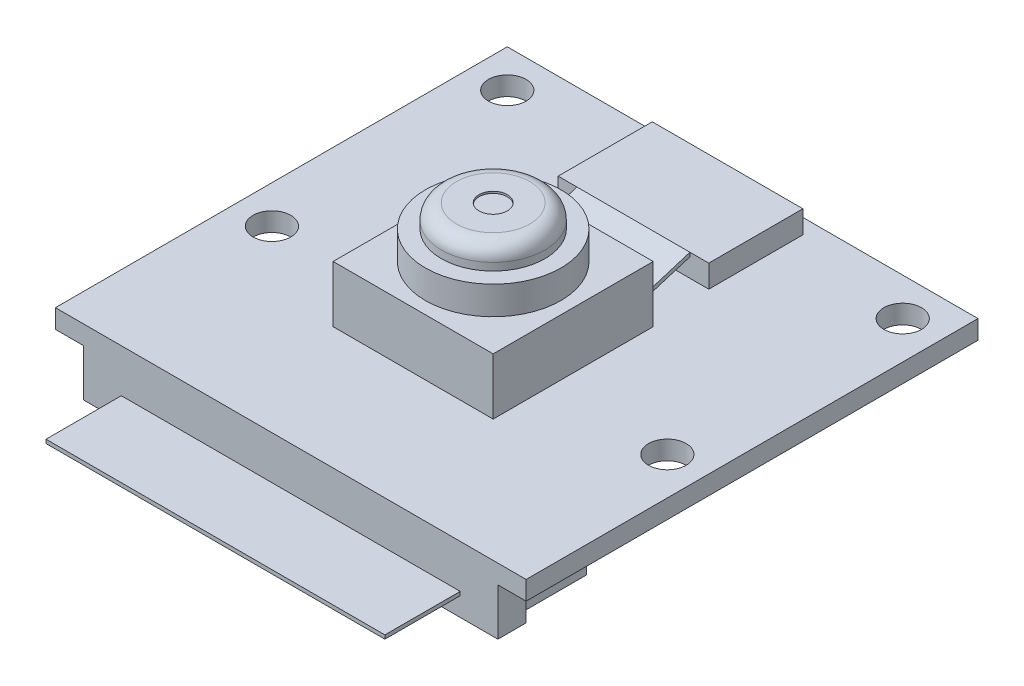
from build123d import *

# Parameters (mm, degrees)
SKETCH_1_W                     = 25
SKETCH_1_H                     = 24
EXTRUDE_1_DEPTH                = 1
CUT_EXTRUDE_1_REACH            = 3
SKETCH_2_R                     = 1
SKETCH_3_W                     = 8.5
SKETCH_3_H                     = 8.5
EXTRUDE_2_DEPTH                = 3
SKETCH_4_R                     = 3.6
EXTRUDE_3_DEPTH                = 1.5
SKETCH_5_R                     = 2.75
EXTRUDE_4_DEPTH                = 1.2
FILLET_1_R                     = 0.8
SKETCH_6_R                     = 0.75
CUT_EXTRUDE_2_DEPTH            = 0.1
SKETCH_7_W                     = 8
SKETCH_7_H                     = 5
EXTRUDE_5_DEPTH                = 1.2
EXTRUDE_6_DEPTH                = 3
EXTRUDE_6_DEPTH_BACK           = 3
SKETCH_9_W                     = 22
SKETCH_9_H                     = 1.5
EXTRUDE_7_DEPTH                = 2.5
SKETCH_12_W                    = 21
SKETCH_12_H                    = 3.7
EXTRUDE_8_DEPTH                = 2.4
EXTRUDE_9_DEPTH                = 0.1
PATTERN_LINEAR_1_COUNT         = 8
PATTERN_LINEAR_1_PITCH         = 1.2
PATTERN_LINEAR_1_COL_COUNT     = 8
PATTERN_LINEAR_1_COL_PITCH     = 1.2
SKETCH_14_W                    = 3
SKETCH_14_H                    = 1.5
EXTRUDE_10_DEPTH               = 1
EXTRUDE_11_DEPTH               = 0.15
PATTERN_LINEAR_2_COUNT         = 2
PATTERN_LINEAR_2_PITCH         = 1
PATTERN_LINEAR_2_COL_COUNT     = 2
PATTERN_LINEAR_2_COL_PITCH     = 1
MIRROR_1_COPY_1_DEPTH          = 0.15
MIRROR_1_COPY_2_DEPTH          = 0.15
PATTERN_LINEAR_3_COUNT         = 3
PATTERN_LINEAR_3_PITCH         = 5
PATTERN_LINEAR_3_COPY_1_DEPTH  = 0.15
PATTERN_LINEAR_3_COPY_2_DEPTH  = 0.15
PATTERN_LINEAR_3_COPY_3_DEPTH  = 0.15
PATTERN_LINEAR_3_COPY_4_DEPTH  = 0.15
PATTERN_LINEAR_3_COPY_5_DEPTH  = 0.15
PATTERN_LINEAR_3_COPY_6_DEPTH  = 0.15
PATTERN_LINEAR_3_COPY_7_DEPTH  = 0.15
PATTERN_LINEAR_3_COPY_8_DEPTH  = 0.15
PATTERN_LINEAR_3_COPY_9_DEPTH  = 0.15
PATTERN_LINEAR_3_COPY_10_DEPTH = 0.15
SKETCH_16_W                    = 2.5
SKETCH_16_H                    = 3
EXTRUDE_12_DEPTH               = 1.2
FILLET_2_R                     = 0.2
SKETCH_17_W                    = 18
SKETCH_17_H                    = 0.2
EXTRUDE_13_DEPTH               = 4


with BuildPart() as part:
    # 草图1 → 凸台-拉伸1 (new body)
    with BuildSketch(Plane(origin=(0, 0, 0), x_dir=(1, 0, 0), z_dir=(0, 1, 0))):
        Rectangle(SKETCH_1_W, SKETCH_1_H)
    extrude(amount=EXTRUDE_1_DEPTH)

    # 草图2 → 切除-拉伸1 (cut, up to next)
    with BuildSketch(Plane(origin=(0, 1, 0), x_dir=(1, 0, 0), z_dir=(0, 1, 0)), mode=Mode.PRIVATE) as cut_extrude_1_sk1:
        with Locations((-10.5, 10)):
            Circle(SKETCH_2_R)
    cut_extrude_1_tool1 = extrude(cut_extrude_1_sk1.sketch, amount=-CUT_EXTRUDE_1_REACH, mode=Mode.PRIVATE) & part.part
    add(cut_extrude_1_tool1.solids().sort_by_distance((-10.5, 1, -10))[0], mode=Mode.SUBTRACT)
    # 草图2 → 切除-拉伸1 (cut, up to next)
    with BuildSketch(Plane(origin=(0, 1, 0), x_dir=(1, 0, 0), z_dir=(0, 1, 0)), mode=Mode.PRIVATE) as cut_extrude_1_sk2:
        with Locations((-10.5, -2.5)):
            Circle(SKETCH_2_R)
    cut_extrude_1_tool2 = extrude(cut_extrude_1_sk2.sketch, amount=-CUT_EXTRUDE_1_REACH, mode=Mode.PRIVATE) & part.part
    add(cut_extrude_1_tool2.solids().sort_by_distance((-10.5, 1, 2.5))[0], mode=Mode.SUBTRACT)
    # 草图2 → 切除-拉伸1 (cut, up to next)
    with BuildSketch(Plane(origin=(0, 1, 0), x_dir=(1, 0, 0), z_dir=(0, 1, 0)), mode=Mode.PRIVATE) as cut_extrude_1_sk3:
        with Locations((10.5, -2.5)):
            Circle(SKETCH_2_R)
    cut_extrude_1_tool3 = extrude(cut_extrude_1_sk3.sketch, amount=-CUT_EXTRUDE_1_REACH, mode=Mode.PRIVATE) & part.part
    add(cut_extrude_1_tool3.solids().sort_by_distance((10.5, 1, 2.5))[0], mode=Mode.SUBTRACT)
    # 草图2 → 切除-拉伸1 (cut, up to next)
    with BuildSketch(Plane(origin=(0, 1, 0), x_dir=(1, 0, 0), z_dir=(0, 1, 0)), mode=Mode.PRIVATE) as cut_extrude_1_sk4:
        with Locations((10.5, 10)):
            Circle(SKETCH_2_R)
    cut_extrude_1_tool4 = extrude(cut_extrude_1_sk4.sketch, amount=-CUT_EXTRUDE_1_REACH, mode=Mode.PRIVATE) & part.part
    add(cut_extrude_1_tool4.solids().sort_by_distance((10.5, 1, -10))[0], mode=Mode.SUBTRACT)

    # 草图3 → 凸台-拉伸2 (add)
    with BuildSketch(Plane(origin=(0, 1, 0), x_dir=(1, 0, 0), z_dir=(0, 1, 0))):
        with Locations((0, -1.25)):
            Rectangle(SKETCH_3_W, SKETCH_3_H)
    extrude(amount=EXTRUDE_2_DEPTH)

    # 草图4 → 凸台-拉伸3 (add)
    with BuildSketch(Plane(origin=(0, 4, 0), x_dir=(1, 0, 0), z_dir=(0, 1, 0))):
        with Locations((0, -1.25)):
            Circle(SKETCH_4_R)
    extrude(amount=EXTRUDE_3_DEPTH)

    # 草图5 → 凸台-拉伸4 (add)
    with BuildSketch(Plane(origin=(0, 5.5, 0), x_dir=(1, 0, 0), z_dir=(0, 1, 0))):
        with Locations((0, -1.25)):
            Circle(SKETCH_5_R)
    extrude(amount=EXTRUDE_4_DEPTH)

    # 圆角1
    fillet_1_edges = [part.edges().sort_by_distance(p)[0] for p in [
        (-2.75, 6.7, 1.25),
    ]]
    fillet(fillet_1_edges, radius=FILLET_1_R)

    # 草图6 → 切除-拉伸2 (cut)
    with BuildSketch(Plane(origin=(0, 6.7, 0), x_dir=(1, 0, 0), z_dir=(0, 1, 0))):
        with Locations((0, -1.25)):
            Circle(SKETCH_6_R)
    extrude(amount=-CUT_EXTRUDE_2_DEPTH, mode=Mode.SUBTRACT)

    # 草图7 → 凸台-拉伸5 (add)
    with BuildSketch(Plane(origin=(0, 1, 0), x_dir=(1, 0, 0), z_dir=(0, 1, 0))):
        with Locations((0, 8.7)):
            Rectangle(SKETCH_7_W, SKETCH_7_H)
    extrude(amount=EXTRUDE_5_DEPTH)

    # 草图9 → 凸台-拉伸7 (add)
    with BuildSketch(Plane.XZ):
        with Locations((0, 11.25)):
            Rectangle(SKETCH_9_W, SKETCH_9_H)
    extrude(amount=EXTRUDE_7_DEPTH)

    # 草图12 → 凸台-拉伸8 (add)
    with BuildSketch(Plane.XZ):
        with Locations((0, 8.65)):
            Rectangle(SKETCH_12_W, SKETCH_12_H)
    extrude(amount=EXTRUDE_8_DEPTH)

    # 草图13 → 凸台-拉伸9 (add, symmetric)
    with BuildSketch(Plane(origin=(0, 0, 0), x_dir=(0, 0, -1), z_dir=(1, 0, 0))):
        Polygon((-6.8, -1.008790538), (-6.177357939, -0.190748293), (-4.987808466, 0), (-4.324702961, 0), (-6.126399675, -0.288908179), (-6.8, -1.173900628), (-6.8, -2.4), (-10.5, -2.4), (-10.5, 0), (-6.8, 0), align=None)
    extrude_9 = extrude(amount=EXTRUDE_9_DEPTH, both=True)

    # 阵列(线性)1: 凸台-拉伸9 ×8
    with Locations(*[(i * PATTERN_LINEAR_1_PITCH, 0, 0) for i in range(1, PATTERN_LINEAR_1_COUNT)]):
        add(extrude_9)

    # 阵列(线性)1 col: 凸台-拉伸9 ×8
    with Locations(*[(-i * PATTERN_LINEAR_1_COL_PITCH, 0, 0) for i in range(1, PATTERN_LINEAR_1_COL_COUNT)]):
        add(extrude_9)

    # 草图14 → 凸台-拉伸10 (add)
    with BuildSketch(Plane.XZ):
        with Locations((7.348338843, -1.449951952)):
            Rectangle(SKETCH_14_W, SKETCH_14_H)
    extrude_10 = extrude(amount=EXTRUDE_10_DEPTH)

    # 草图15 → 凸台-拉伸11 (add, symmetric)
    with BuildSketch(Plane(origin=(7.348338843, 0, 0), x_dir=(0, 0, -1), z_dir=(1, 0, 0))):
        Polygon((0.699951952, -0.5), (0.494820472, -0.16628555), (-0.186525175, 0), (0.235245417, 0), (0.558478735, -0.078886583), (0.699951952, -0.309039736), (0.699951952, 0), (2.199951952, 0), (2.199951952, -1), (0.699951952, -1), align=None)
    extrude_11 = extrude(amount=EXTRUDE_11_DEPTH, both=True)

    # 阵列(线性)2: 凸台-拉伸11 ×2
    with Locations(*[(-i * PATTERN_LINEAR_2_PITCH, 0, 0) for i in range(1, PATTERN_LINEAR_2_COUNT)]):
        add(extrude_11)

    # 阵列(线性)2 col: 凸台-拉伸11 ×2
    with Locations(*[(i * PATTERN_LINEAR_2_COL_PITCH, 0, 0) for i in range(1, PATTERN_LINEAR_2_COL_COUNT)]):
        add(extrude_11)

    # 镜向1: 凸台-拉伸11 across plane
    add(extrude_11.mirror(Plane.XY.offset(-1.449951952)))

    # 镜向1 copy 1 sketch → 镜向1 copy 1 (add, symmetric)
    with BuildSketch(Plane(origin=(6.348338843, 0, -2.899903905), x_dir=(0, 0, 1), z_dir=(1, 0, 0))):
        Polygon((0.699951952, 0.5), (0.494820472, 0.16628555), (-0.186525175, 0), (0.235245417, 0), (0.558478735, 0.078886583), (0.699951952, 0.309039736), (0.699951952, 0), (2.199951952, 0), (2.199951952, 1), (0.699951952, 1), align=None)
    extrude(amount=MIRROR_1_COPY_1_DEPTH, both=True)

    # 镜向1 copy 2 sketch → 镜向1 copy 2 (add, symmetric)
    with BuildSketch(Plane(origin=(8.348338843, 0, -2.899903905), x_dir=(0, 0, 1), z_dir=(1, 0, 0))):
        Polygon((0.699951952, 0.5), (0.494820472, 0.16628555), (-0.186525175, 0), (0.235245417, 0), (0.558478735, 0.078886583), (0.699951952, 0.309039736), (0.699951952, 0), (2.199951952, 0), (2.199951952, 1), (0.699951952, 1), align=None)
    extrude(amount=MIRROR_1_COPY_2_DEPTH, both=True)

    # 阵列(线性)3: 凸台-拉伸11, 凸台-拉伸10 ×3
    with Locations(*[(-i * PATTERN_LINEAR_3_PITCH, 0, 0) for i in range(1, PATTERN_LINEAR_3_COUNT)]):
        add(extrude_11)
        add(extrude_10)

    # 阵列(线性)3 copy 1 sketch → 阵列(线性)3 copy 1 (add, symmetric)
    with BuildSketch(Plane(origin=(2.348338843, 0, -2.899903905), x_dir=(0, 0, 1), z_dir=(1, 0, 0))):
        Polygon((0.699951952, 0.5), (0.494820472, 0.16628555), (-0.186525175, 0), (0.235245417, 0), (0.558478735, 0.078886583), (0.699951952, 0.309039736), (0.699951952, 0), (2.199951952, 0), (2.199951952, 1), (0.699951952, 1), align=None)
    extrude(amount=PATTERN_LINEAR_3_COPY_1_DEPTH, both=True)

    # 阵列(线性)3 copy 2 sketch → 阵列(线性)3 copy 2 (add, symmetric)
    with BuildSketch(Plane(origin=(-2.651661157, 0, -2.899903905), x_dir=(0, 0, 1), z_dir=(1, 0, 0))):
        Polygon((0.699951952, 0.5), (0.494820472, 0.16628555), (-0.186525175, 0), (0.235245417, 0), (0.558478735, 0.078886583), (0.699951952, 0.309039736), (0.699951952, 0), (2.199951952, 0), (2.199951952, 1), (0.699951952, 1), align=None)
    extrude(amount=PATTERN_LINEAR_3_COPY_2_DEPTH, both=True)

    # 阵列(线性)3 copy 3 sketch → 阵列(线性)3 copy 3 (add, symmetric)
    with BuildSketch(Plane(origin=(1.348338843, 0, -2.899903905), x_dir=(0, 0, 1), z_dir=(1, 0, 0))):
        Polygon((0.699951952, 0.5), (0.494820472, 0.16628555), (-0.186525175, 0), (0.235245417, 0), (0.558478735, 0.078886583), (0.699951952, 0.309039736), (0.699951952, 0), (2.199951952, 0), (2.199951952, 1), (0.699951952, 1), align=None)
    extrude(amount=PATTERN_LINEAR_3_COPY_3_DEPTH, both=True)

    # 阵列(线性)3 copy 4 sketch → 阵列(线性)3 copy 4 (add, symmetric)
    with BuildSketch(Plane(origin=(-3.651661157, 0, -2.899903905), x_dir=(0, 0, 1), z_dir=(1, 0, 0))):
        Polygon((0.699951952, 0.5), (0.494820472, 0.16628555), (-0.186525175, 0), (0.235245417, 0), (0.558478735, 0.078886583), (0.699951952, 0.309039736), (0.699951952, 0), (2.199951952, 0), (2.199951952, 1), (0.699951952, 1), align=None)
    extrude(amount=PATTERN_LINEAR_3_COPY_4_DEPTH, both=True)

    # 阵列(线性)3 copy 5 sketch → 阵列(线性)3 copy 5 (add, symmetric)
    with BuildSketch(Plane(origin=(3.348338843, 0, -2.899903905), x_dir=(0, 0, 1), z_dir=(1, 0, 0))):
        Polygon((0.699951952, 0.5), (0.494820472, 0.16628555), (-0.186525175, 0), (0.235245417, 0), (0.558478735, 0.078886583), (0.699951952, 0.309039736), (0.699951952, 0), (2.199951952, 0), (2.199951952, 1), (0.699951952, 1), align=None)
    extrude(amount=PATTERN_LINEAR_3_COPY_5_DEPTH, both=True)

    # 阵列(线性)3 copy 6 sketch → 阵列(线性)3 copy 6 (add, symmetric)
    with BuildSketch(Plane(origin=(-1.651661157, 0, -2.899903905), x_dir=(0, 0, 1), z_dir=(1, 0, 0))):
        Polygon((0.699951952, 0.5), (0.494820472, 0.16628555), (-0.186525175, 0), (0.235245417, 0), (0.558478735, 0.078886583), (0.699951952, 0.309039736), (0.699951952, 0), (2.199951952, 0), (2.199951952, 1), (0.699951952, 1), align=None)
    extrude(amount=PATTERN_LINEAR_3_COPY_6_DEPTH, both=True)

    # 阵列(线性)3 copy 7 sketch → 阵列(线性)3 copy 7 (add, symmetric)
    with BuildSketch(Plane(origin=(1.348338843, 0, 0), x_dir=(0, 0, -1), z_dir=(1, 0, 0))):
        Polygon((0.699951952, -0.5), (0.494820472, -0.16628555), (-0.186525175, 0), (0.235245417, 0), (0.558478735, -0.078886583), (0.699951952, -0.309039736), (0.699951952, 0), (2.199951952, 0), (2.199951952, -1), (0.699951952, -1), align=None)
    extrude(amount=PATTERN_LINEAR_3_COPY_7_DEPTH, both=True)

    # 阵列(线性)3 copy 8 sketch → 阵列(线性)3 copy 8 (add, symmetric)
    with BuildSketch(Plane(origin=(-3.651661157, 0, 0), x_dir=(0, 0, -1), z_dir=(1, 0, 0))):
        Polygon((0.699951952, -0.5), (0.494820472, -0.16628555), (-0.186525175, 0), (0.235245417, 0), (0.558478735, -0.078886583), (0.699951952, -0.309039736), (0.699951952, 0), (2.199951952, 0), (2.199951952, -1), (0.699951952, -1), align=None)
    extrude(amount=PATTERN_LINEAR_3_COPY_8_DEPTH, both=True)

    # 阵列(线性)3 copy 9 sketch → 阵列(线性)3 copy 9 (add, symmetric)
    with BuildSketch(Plane(origin=(3.348338843, 0, 0), x_dir=(0, 0, -1), z_dir=(1, 0, 0))):
        Polygon((0.699951952, -0.5), (0.494820472, -0.16628555), (-0.186525175, 0), (0.235245417, 0), (0.558478735, -0.078886583), (0.699951952, -0.309039736), (0.699951952, 0), (2.199951952, 0), (2.199951952, -1), (0.699951952, -1), align=None)
    extrude(amount=PATTERN_LINEAR_3_COPY_9_DEPTH, both=True)

    # 阵列(线性)3 copy 10 sketch → 阵列(线性)3 copy 10 (add, symmetric)
    with BuildSketch(Plane(origin=(-1.651661157, 0, 0), x_dir=(0, 0, -1), z_dir=(1, 0, 0))):
        Polygon((0.699951952, -0.5), (0.494820472, -0.16628555), (-0.186525175, 0), (0.235245417, 0), (0.558478735, -0.078886583), (0.699951952, -0.309039736), (0.699951952, 0), (2.199951952, 0), (2.199951952, -1), (0.699951952, -1), align=None)
    extrude(amount=PATTERN_LINEAR_3_COPY_10_DEPTH, both=True)

    # 草图16 → 凸台-拉伸12 (add)
    with BuildSketch(Plane.XZ):
        with Locations((-7.364219921, -6.992205414)):
            Rectangle(SKETCH_16_W, SKETCH_16_H)
    extrude(amount=EXTRUDE_12_DEPTH)

    # 圆角2
    fillet_2_edges = [part.edges().sort_by_distance(p)[0] for p in [
        (2.348338843, -0.16628555, -0.494820472),
        (2.348338843, -0.078886583, -0.558478735),
        (-2.651661157, -0.16628555, -0.494820472),
        (-2.651661157, -0.078886583, -0.558478735),
        (3.348338843, -0.16628555, -0.494820472),
        (3.348338843, -0.078886583, -0.558478735),
        (1.348338843, -0.16628555, -0.494820472),
        (1.348338843, -0.078886583, -0.558478735),
        (-1.651661157, -0.16628555, -0.494820472),
        (-1.651661157, -0.078886583, -0.558478735),
        (-3.651661157, -0.16628555, -0.494820472),
        (-3.651661157, -0.078886583, -0.558478735),
        (2.348338843, -0.078886583, -2.341425169),
        (2.348338843, -0.16628555, -2.405083432),
        (3.348338843, -0.078886583, -2.341425169),
        (3.348338843, -0.16628555, -2.405083432),
        (1.348338843, -0.078886583, -2.341425169),
        (1.348338843, -0.16628555, -2.405083432),
        (-2.651661157, -0.078886583, -2.341425169),
        (-2.651661157, -0.16628555, -2.405083432),
        (-1.651661157, -0.078886583, -2.341425169),
        (-1.651661157, -0.16628555, -2.405083432),
        (-3.651661157, -0.078886583, -2.341425169),
        (-3.651661157, -0.16628555, -2.405083432),
        (-6.114219921, -1.2, -6.992205414),
        (-7.364219921, -1.2, -5.492205414),
        (-8.614219921, -1.2, -6.992205414),
        (-7.364219921, -1.2, -8.492205414),
        (8.848338843, -1, -1.449951952),
        (7.348338843, -1, -0.699951952),
        (5.848338843, -1, -1.449951952),
        (7.348338843, -1, -2.199951952),
        (7.348338843, -0.16628555, -0.494820472),
        (7.348338843, -0.078886583, -0.558478735),
        (8.348338843, -0.16628555, -0.494820472),
        (8.348338843, -0.078886583, -0.558478735),
        (6.348338843, -0.16628555, -0.494820472),
        (6.348338843, -0.078886583, -0.558478735),
        (7.348338843, -0.078886583, -2.341425169),
        (7.348338843, -0.16628555, -2.405083432),
        (8.348338843, -0.078886583, -2.341425169),
        (8.348338843, -0.16628555, -2.405083432),
        (6.348338843, -0.078886583, -2.341425169),
        (6.348338843, -0.16628555, -2.405083432),
        (3.848338843, -1, -1.449951952),
        (2.348338843, -1, -0.699951952),
        (0.848338843, -1, -1.449951952),
        (2.348338843, -1, -2.199951952),
        (-1.151661157, -1, -1.449951952),
        (-2.651661157, -1, -0.699951952),
        (-4.151661157, -1, -1.449951952),
        (-2.651661157, -1, -2.199951952),
    ]]
    fillet(fillet_2_edges, radius=FILLET_2_R)

    # 草图17 → 凸台-拉伸13 (add)
    with BuildSketch(Plane.XY.offset(12)):
        with Locations((0, -1.4)):
            Rectangle(SKETCH_17_W, SKETCH_17_H)
    extrude(amount=EXTRUDE_13_DEPTH)


with BuildPart() as body_2:
    # 草图8 → 凸台-拉伸6 (new body, two sides)
    with BuildSketch(Plane(origin=(0, 0, 0), x_dir=(0, 0, -1), z_dir=(1, 0, 0))) as extrude_6_sk:
        Polygon((3, 1.209364356), (6.2, 2.2), (6.2, 1.990635644), (3, 1), align=None)
    extrude(amount=EXTRUDE_6_DEPTH)
    extrude(extrude_6_sk.sketch, amount=-EXTRUDE_6_DEPTH_BACK)


solid = Compound([part.part, body_2.part])
